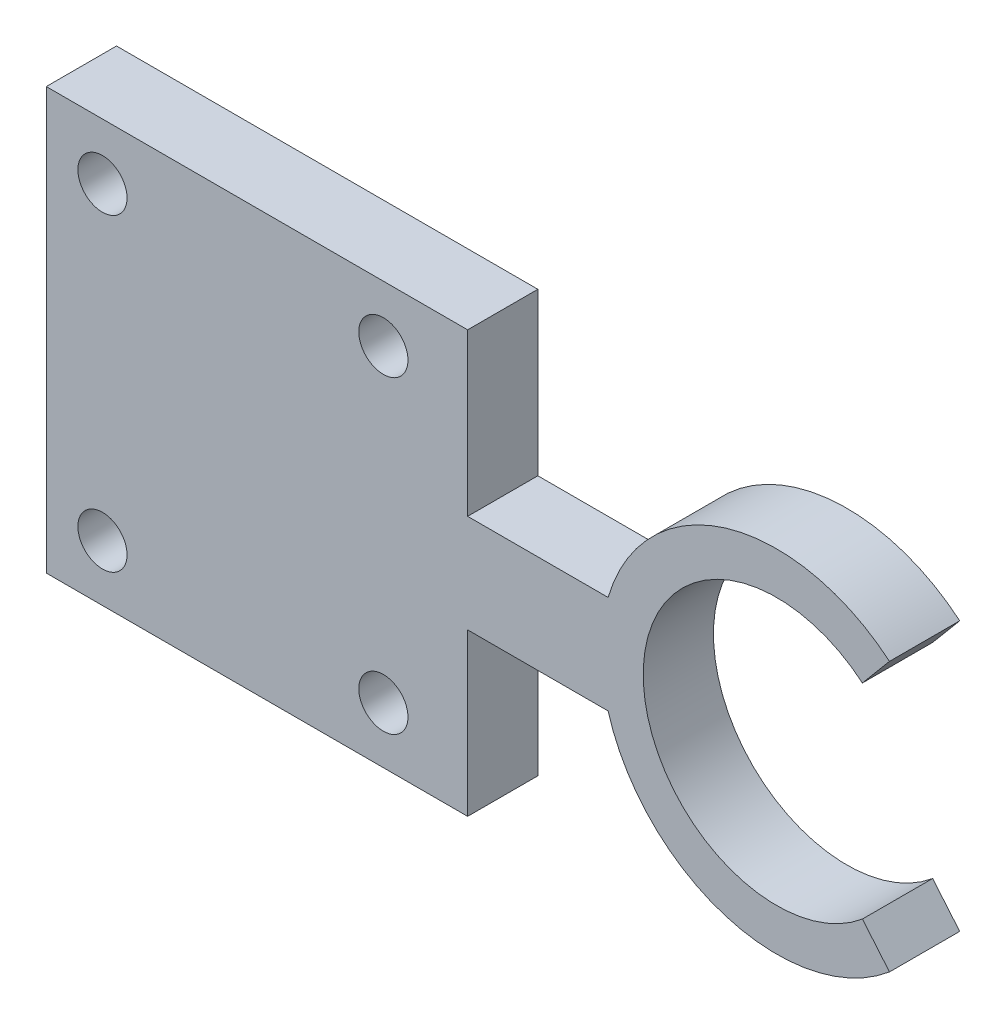
from build123d import *

# Parameters (mm, degrees)
ESBO_O14_W               = 40
ESBO_O14_H               = 5
RESSALTO_EXTRUS_O1_DEPTH = 3.5
ESBO_O15_W               = 30
ESBO_O15_H               = 30
ESBO_O15_R               = 1.75
RESSALTO_EXTRUS_O2_DEPTH = 5


with BuildPart() as part:
    # Esboço14 → Ressalto-extrusão1 (new, symmetric)
    with BuildSketch(Plane(origin=(0, 0, 0), x_dir=(1, 0, 0), z_dir=(0, 1, 0))):
        with Locations((-32, 0)):
            Rectangle(ESBO_O14_W, ESBO_O14_H)
    extrude(amount=RESSALTO_EXTRUS_O1_DEPTH, both=True)

    # Varredura1: sweep along a path in Esboço1
    with BuildLine(Plane.XY) as varredura1_path:
        ThreePointArc((7.070663707, 8.426488874), (-11, 0), (7.070663707, -8.426488874))
    # 3DSketch2 → Varredura1 (sweep)
    with BuildSketch(Plane(origin=(8.034845121, -9.575555539, 2.5), x_dir=(-0.33071149682512846, 0.39412661445355873, -0.8574929257125443), z_dir=(0.7660444431189768, 0.6427876096865409, 3.624573608241852e-15))):
        Polygon((0, 0), (1.543487266, 2.572478777), (5.830951895, 0), (4.287464629, -2.572478777), align=None)
    sweep(path=varredura1_path.line)

    # Esboço15 → Ressalto-extrusão2 (add)
    with BuildSketch(Plane.XY.offset(2.5)):
        with Locations((-37, 0)):
            Rectangle(ESBO_O15_W, ESBO_O15_H)
        with Locations((-48, 11)):
            Circle(ESBO_O15_R, mode=Mode.SUBTRACT)
        with Locations((-28, 11)):
            Circle(ESBO_O15_R, mode=Mode.SUBTRACT)
        with Locations((-28, -11)):
            Circle(ESBO_O15_R, mode=Mode.SUBTRACT)
        with Locations((-48, -11)):
            Circle(ESBO_O15_R, mode=Mode.SUBTRACT)
    extrude(amount=-RESSALTO_EXTRUS_O2_DEPTH)


solid = part.part
